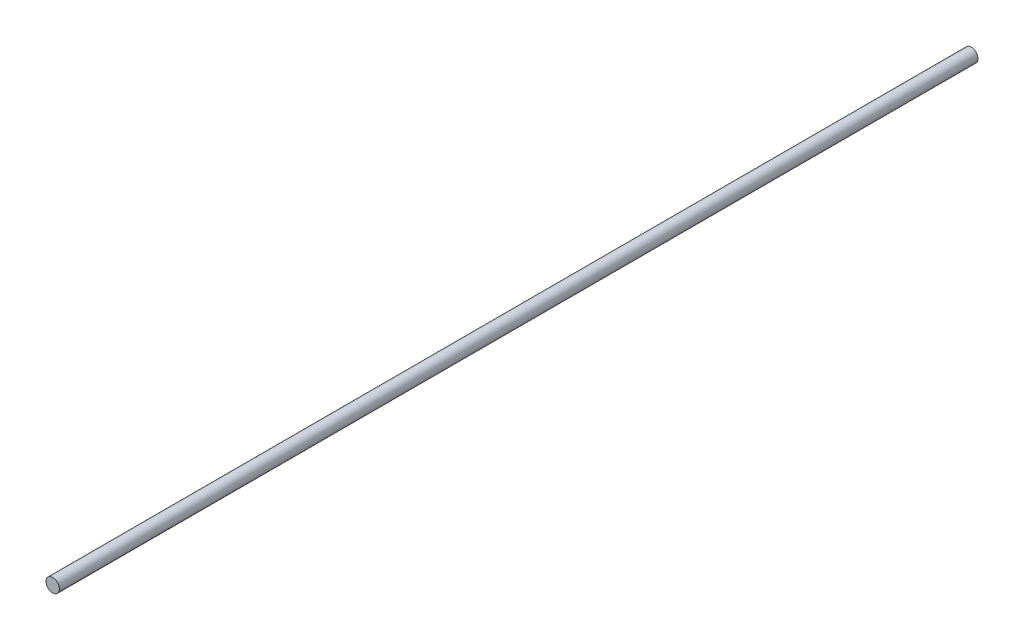
from build123d import *

# Parameters (mm, degrees)
SKETCH1_R           = 4
BOSS_EXTRUDE1_DEPTH = 550


with BuildPart() as part:
    # Sketch1 → Boss-Extrude1 (new body)
    with BuildSketch(Plane.XY):
        Circle(SKETCH1_R)
    extrude(amount=BOSS_EXTRUDE1_DEPTH)


solid = part.part
